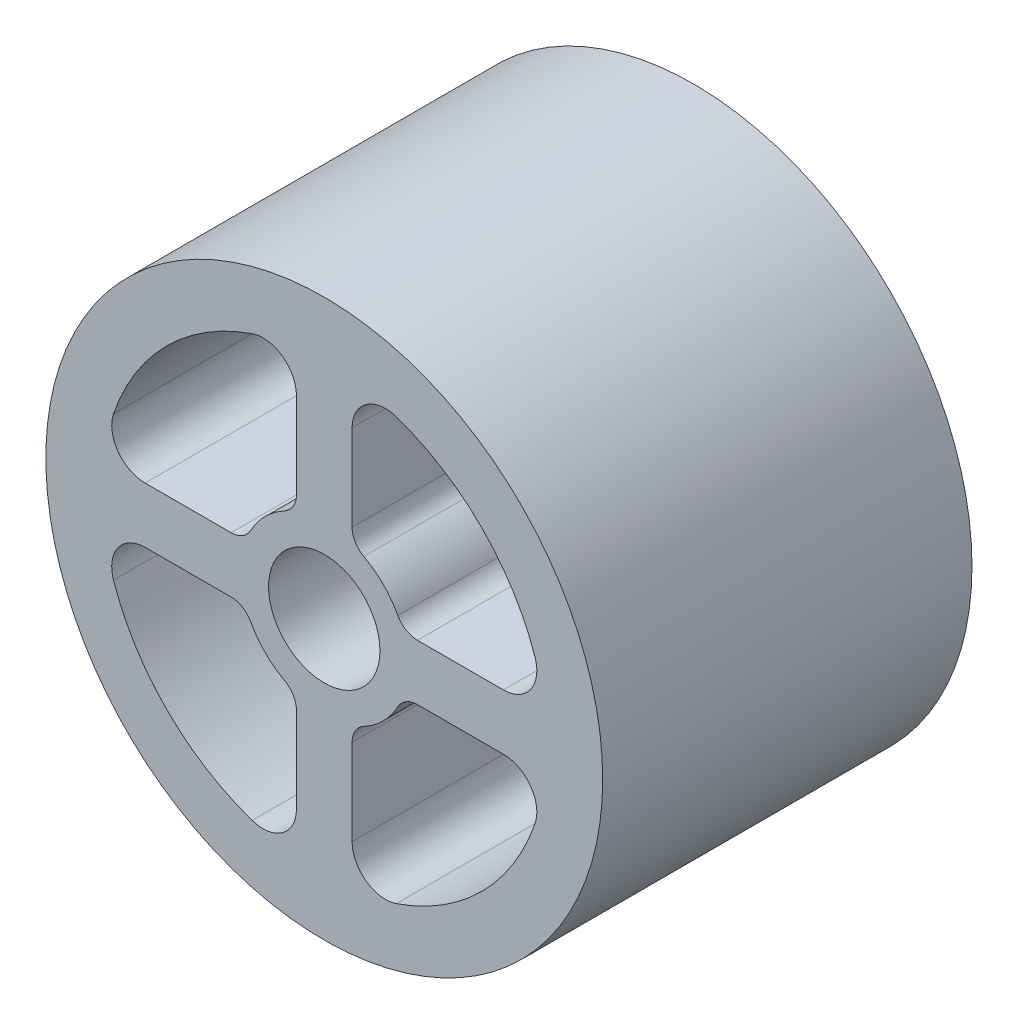
from build123d import *

# Parameters (mm, degrees)
IZIM1_R                     = 47.5
IZIM1_R_2                   = 9.5
Y_KSEKLIK_EKSTR_ZYON1_DEPTH = 63


with BuildPart() as part:
    # Çizim1 → Yükseklik-Ekstrüzyon1 (new body)
    with BuildSketch(Plane.XY):
        Circle(IZIM1_R)
        Circle(IZIM1_R_2, mode=Mode.SUBTRACT)
        with BuildLine():
            Line((30.56284509, 4.75), (15.896540504, 4.75))
            ThreePointArc((15.896540504, 4.75), (13.947181635, 5.288098714), (12.549900398, 6.75))
            ThreePointArc((12.549900398, 6.75), (10.076271632, 10.076271632), (6.75, 12.549900398))
            ThreePointArc((6.75, 12.549900398), (5.288098714, 13.947181635), (4.75, 15.896540504))
            Line((4.75, 15.896540504), (4.75, 30.56284509))
            ThreePointArc((4.75, 30.56284509), (7.134994011, 35.199733626), (12.294117647, 35.956288341))
            ThreePointArc((12.294117647, 35.956288341), (26.870057685, 26.870057685), (35.956288341, 12.294117647))
            ThreePointArc((35.956288341, 12.294117647), (35.199733626, 7.134994011), (30.56284509, 4.75))
        make_face(mode=Mode.SUBTRACT)
        with BuildLine():
            Line((-30.56284509, 4.75), (-15.896540504, 4.75))
            ThreePointArc((-15.896540504, 4.75), (-13.947181635, 5.288098714), (-12.549900398, 6.75))
            ThreePointArc((-12.549900398, 6.75), (-10.076271632, 10.076271632), (-6.75, 12.549900398))
            ThreePointArc((-6.75, 12.549900398), (-5.288098714, 13.947181635), (-4.75, 15.896540504))
            Line((-4.75, 15.896540504), (-4.75, 30.56284509))
            ThreePointArc((-4.75, 30.56284509), (-7.134994011, 35.199733626), (-12.294117647, 35.956288341))
            ThreePointArc((-12.294117647, 35.956288341), (-26.870057685, 26.870057685), (-35.956288341, 12.294117647))
            ThreePointArc((-35.956288341, 12.294117647), (-35.199733626, 7.134994011), (-30.56284509, 4.75))
        make_face(mode=Mode.SUBTRACT)
        with BuildLine():
            Line((4.75, -30.56284509), (4.75, -15.896540504))
            ThreePointArc((4.75, -15.896540504), (5.288098714, -13.947181635), (6.75, -12.549900398))
            ThreePointArc((6.75, -12.549900398), (10.076271632, -10.076271632), (12.549900398, -6.75))
            ThreePointArc((12.549900398, -6.75), (13.947181635, -5.288098714), (15.896540504, -4.75))
            Line((15.896540504, -4.75), (30.56284509, -4.75))
            ThreePointArc((30.56284509, -4.75), (35.199733626, -7.134994011), (35.956288341, -12.294117647))
            ThreePointArc((35.956288341, -12.294117647), (26.870057685, -26.870057685), (12.294117647, -35.956288341))
            ThreePointArc((12.294117647, -35.956288341), (7.134994011, -35.199733626), (4.75, -30.56284509))
        make_face(mode=Mode.SUBTRACT)
        with BuildLine():
            Line((-30.56284509, -4.75), (-15.896540504, -4.75))
            ThreePointArc((-15.896540504, -4.75), (-13.947181635, -5.288098714), (-12.549900398, -6.75))
            ThreePointArc((-12.549900398, -6.75), (-10.076271632, -10.076271632), (-6.75, -12.549900398))
            ThreePointArc((-6.75, -12.549900398), (-5.288098714, -13.947181635), (-4.75, -15.896540504))
            Line((-4.75, -15.896540504), (-4.75, -30.56284509))
            ThreePointArc((-4.75, -30.56284509), (-7.134994011, -35.199733626), (-12.294117647, -35.956288341))
            ThreePointArc((-12.294117647, -35.956288341), (-26.870057685, -26.870057685), (-35.956288341, -12.294117647))
            ThreePointArc((-35.956288341, -12.294117647), (-35.199733626, -7.134994011), (-30.56284509, -4.75))
        make_face(mode=Mode.SUBTRACT)
    extrude(amount=Y_KSEKLIK_EKSTR_ZYON1_DEPTH)


solid = part.part
